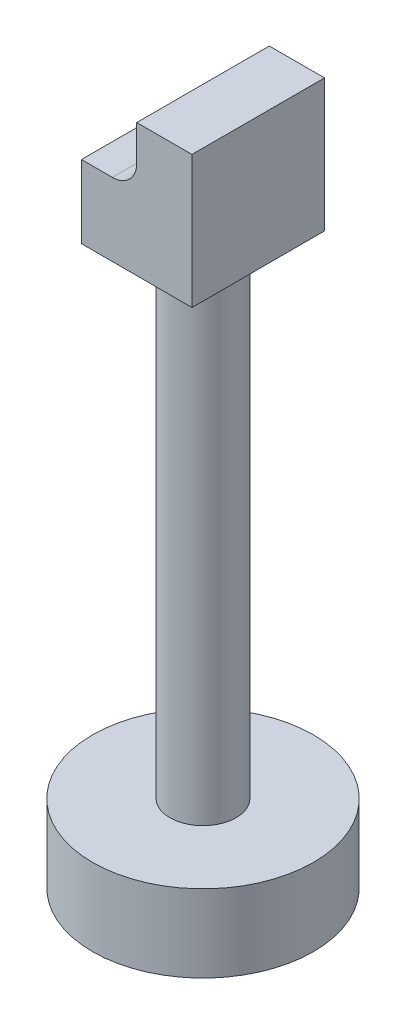
from build123d import *

# Parameters (mm, degrees)
SKETCH1_R           = 50
BOSS_EXTRUDE1_DEPTH = 35
SKETCH2_R           = 15
BOSS_EXTRUDE2_DEPTH = 220
SKETCH3_W           = 50
SKETCH3_H           = 60
BOSS_EXTRUDE3_DEPTH = 60
CUT_EXTRUDE1_DEPTH  = 81


with BuildPart() as part:
    # Sketch1 → Boss-Extrude1 (new body)
    with BuildSketch(Plane(origin=(0, 0, 0), x_dir=(1, 0, 0), z_dir=(0, 1, 0))):
        Circle(SKETCH1_R)
    extrude(amount=BOSS_EXTRUDE1_DEPTH)

    # Sketch2 → Boss-Extrude2 (add)
    with BuildSketch(Plane(origin=(0, 35, 0), x_dir=(1, 0, 0), z_dir=(0, 1, 0))):
        Circle(SKETCH2_R)
    extrude(amount=BOSS_EXTRUDE2_DEPTH)

    # Sketch3 → Boss-Extrude3 (add)
    with BuildSketch(Plane(origin=(0, 255, 0), x_dir=(1, 0, 0), z_dir=(0, 1, 0))):
        Rectangle(SKETCH3_W, SKETCH3_H)
    extrude(amount=BOSS_EXTRUDE3_DEPTH)

    # Sketch4 → Cut-Extrude1 (cut, through all)
    with BuildSketch(Plane.XY.offset(30)):
        with BuildLine():
            Line((0, 315), (0, 299))
            ThreePointArc((0, 299), (-3.221825407, 291.221825407), (-11, 288))
            Line((-11, 288), (-25, 288))
            Line((-25, 288), (-25, 315))
            Line((-25, 315), (0, 315))
        make_face()
    extrude(amount=-CUT_EXTRUDE1_DEPTH, mode=Mode.SUBTRACT)


solid = part.part
